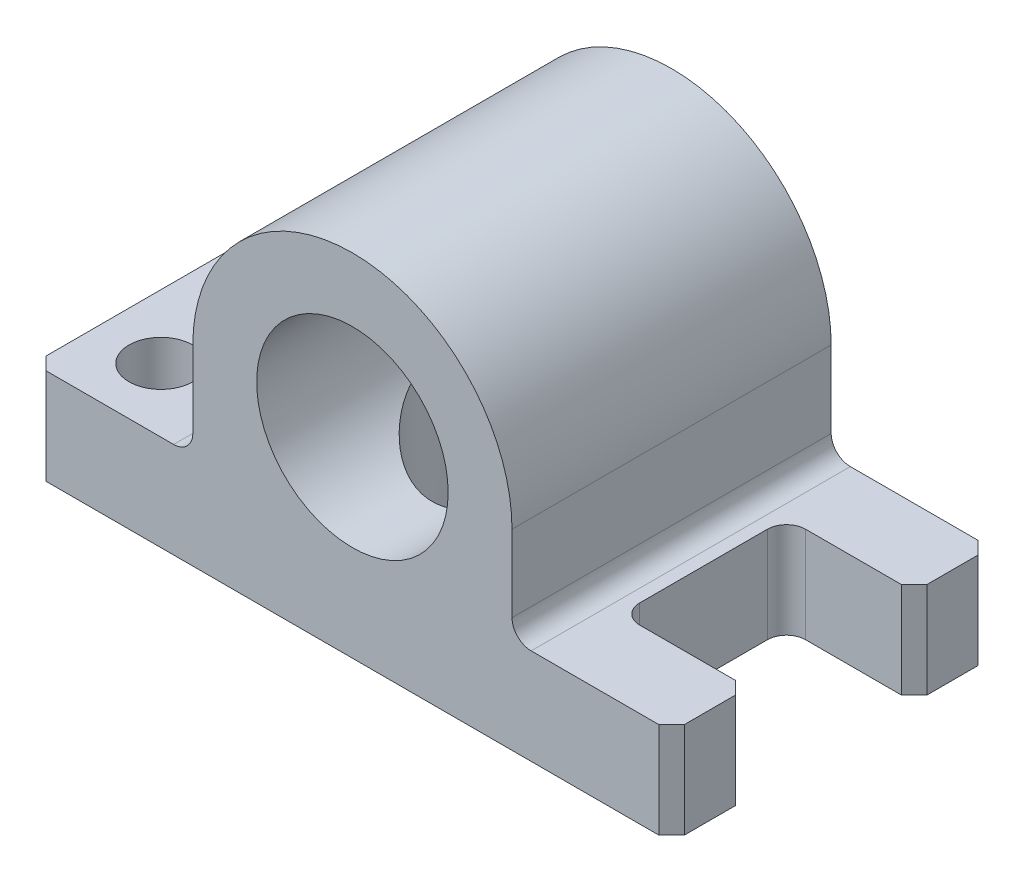
from build123d import *

# Parameters (mm, degrees)
SKETCH1_R           = 15
BOSS_EXTRUDE2_DEPTH = 25
CUT_EXTRUDE1_REACH  = 57
SKETCH3_R           = 12.5
SKETCH3_R_2         = 5
CUT_EXTRUDE2_REACH  = 57
SKETCH5_W           = 20
SKETCH5_H           = 26
FILLET2_R           = 3
CHAMFER1_SIZE       = 2


with BuildPart() as part:
    # Sketch1 → Boss-Extrude2 (new body, symmetric)
    with BuildSketch(Plane.XY):
        with BuildLine():
            Line((-50, -30), (50, -30))
            Line((50, -30), (50, -15))
            Line((50, -15), (25, -15))
            Line((25, -15), (25, 0))
            ThreePointArc((25, 0), (0, 25), (-25, 0))
            Line((-25, 0), (-25, -15))
            Line((-25, -15), (-50, -15))
            Line((-50, -15), (-50, -30))
        make_face()
        Circle(SKETCH1_R, mode=Mode.SUBTRACT)
    extrude(amount=BOSS_EXTRUDE2_DEPTH, both=True)

    # Sketch3 → Cut-Extrude1 (cut, up to next)
    with BuildSketch(Plane.XZ.offset(30), mode=Mode.PRIVATE) as cut_extrude1_sk1:
        Circle(SKETCH3_R)
    cut_extrude1_tool1 = extrude(cut_extrude1_sk1.sketch, amount=-CUT_EXTRUDE1_REACH, mode=Mode.PRIVATE) & part.part
    add(cut_extrude1_tool1.solids().sort_by_distance((0, -30, 0))[0], mode=Mode.SUBTRACT)
    # Sketch3 → Cut-Extrude1 (cut, up to next)
    with BuildSketch(Plane.XZ.offset(30), mode=Mode.PRIVATE) as cut_extrude1_sk2:
        with Locations((-40, 15)):
            Circle(SKETCH3_R_2)
    cut_extrude1_tool2 = extrude(cut_extrude1_sk2.sketch, amount=-CUT_EXTRUDE1_REACH, mode=Mode.PRIVATE) & part.part
    add(cut_extrude1_tool2.solids().sort_by_distance((-40, -30, 15))[0], mode=Mode.SUBTRACT)
    # Sketch3 → Cut-Extrude1 (cut, up to next)
    with BuildSketch(Plane.XZ.offset(30), mode=Mode.PRIVATE) as cut_extrude1_sk3:
        with Locations((-40, -15)):
            Circle(SKETCH3_R_2)
    cut_extrude1_tool3 = extrude(cut_extrude1_sk3.sketch, amount=-CUT_EXTRUDE1_REACH, mode=Mode.PRIVATE) & part.part
    add(cut_extrude1_tool3.solids().sort_by_distance((-40, -30, -15))[0], mode=Mode.SUBTRACT)

    # Sketch5 → Cut-Extrude2 (cut, up to next)
    with BuildSketch(Plane.XZ.offset(30), mode=Mode.PRIVATE) as cut_extrude2_sk1:
        with Locations((40, 0)):
            Rectangle(SKETCH5_W, SKETCH5_H)
    cut_extrude2_tool1 = extrude(cut_extrude2_sk1.sketch, amount=-CUT_EXTRUDE2_REACH, mode=Mode.PRIVATE) & part.part
    add(cut_extrude2_tool1.solids().sort_by_distance((40, -30, 0))[0], mode=Mode.SUBTRACT)

    # Fillet2
    fillet2_edges = [part.edges().sort_by_distance(p)[0] for p in [
        (-25, -15, 0),
        (25, -15, 0),
        (30, -22.5, -13),
        (30, -22.5, 13),
    ]]
    fillet(fillet2_edges, radius=FILLET2_R)

    # Chamfer1
    chamfer1_edges = [part.edges().sort_by_distance(p)[0] for p in [
        (50, -22.5, -25),
        (-50, -22.5, -25),
        (50, -22.5, 25),
        (50, -22.5, 13),
        (50, -22.5, -13),
        (-50, -22.5, 25),
    ]]
    chamfer(chamfer1_edges, length=CHAMFER1_SIZE)


solid = part.part
